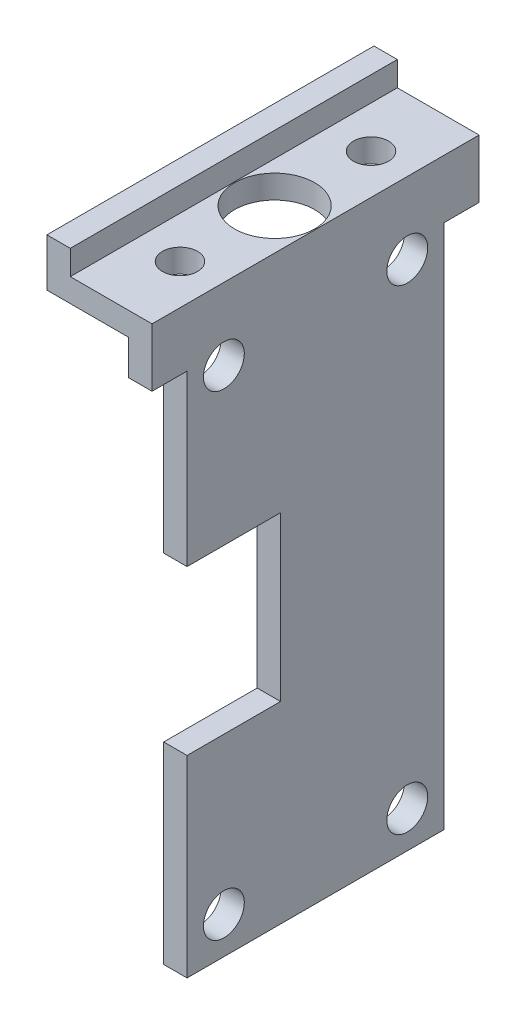
from build123d import *

# Parameters (mm, degrees)
BOSS_EXTRUDE3_DEPTH = 28
SKETCH4_R           = 3.43
SKETCH4_R_2         = 1.5
CUT_EXTRUDE1_DEPTH  = 2
SKETCH6_W           = 3
SKETCH6_H           = 45
CUT_EXTRUDE4_DEPTH  = 2
SKETCH7_R           = 1.75
CUT_EXTRUDE5_DEPTH  = 3
SKETCH10_W          = 8
SKETCH10_H          = 14
CUT_EXTRUDE7_DEPTH  = 10


with BuildPart() as part:
    # Sketch3 → Boss-Extrude3 (new body)
    with BuildSketch(Plane.XY):
        Polygon((-16.953175304, 6.6875), (-14.953175304, 6.6875), (-14.953175304, 4.5875), (-7.953175304, 4.5875), (-7.953175304, -45.4125), (-9.953175304, -45.4125), (-9.953175304, 2.5875), (-16.953175304, 2.5875), align=None)
    extrude(amount=BOSS_EXTRUDE3_DEPTH)

    # Sketch4 → Cut-Extrude1 (cut)
    with BuildSketch(Plane(origin=(0, 4.5875, 0), x_dir=(1, 0, 0), z_dir=(0, 1, 0))):
        with Locations((-11.458423587, -14)):
            Circle(SKETCH4_R)
        with Locations((-11.383175304, -5.822)):
            Circle(SKETCH4_R_2)
        with Locations((-11.383175304, -22.177653801)):
            Circle(SKETCH4_R_2)
    extrude(amount=-CUT_EXTRUDE1_DEPTH, mode=Mode.SUBTRACT)

    # Sketch6 → Cut-Extrude4 (cut)
    with BuildSketch(Plane(origin=(-7.953175304, 0, 0), x_dir=(0, 0, -1), z_dir=(1, 0, 0))):
        with Locations((-26.5, -22.9125)):
            Rectangle(SKETCH6_W, SKETCH6_H)
        with Locations((-1.5, -22.9125)):
            Rectangle(SKETCH6_W, SKETCH6_H)
    extrude(amount=-CUT_EXTRUDE4_DEPTH, mode=Mode.SUBTRACT)

    # Sketch7 → Cut-Extrude5 (cut, through all)
    with BuildSketch(Plane.ZY.offset(9.953175304)):
        with Locations((21.85, -42.2625)):
            Circle(SKETCH7_R)
        with Locations((6.15, -42.2625)):
            Circle(SKETCH7_R)
        with Locations((6.15, -1.5625)):
            Circle(SKETCH7_R)
        with Locations((21.85, -1.5625)):
            Circle(SKETCH7_R)
    extrude(amount=-CUT_EXTRUDE5_DEPTH, mode=Mode.SUBTRACT)

    # Sketch10 → Cut-Extrude7 (cut, through all)
    with BuildSketch(Plane(origin=(-7.953175304, 0, 0), x_dir=(0, 0, -1), z_dir=(1, 0, 0))):
        with Locations((-21, -21.9125)):
            Rectangle(SKETCH10_W, SKETCH10_H)
    extrude(amount=-CUT_EXTRUDE7_DEPTH, mode=Mode.SUBTRACT)


solid = part.part
